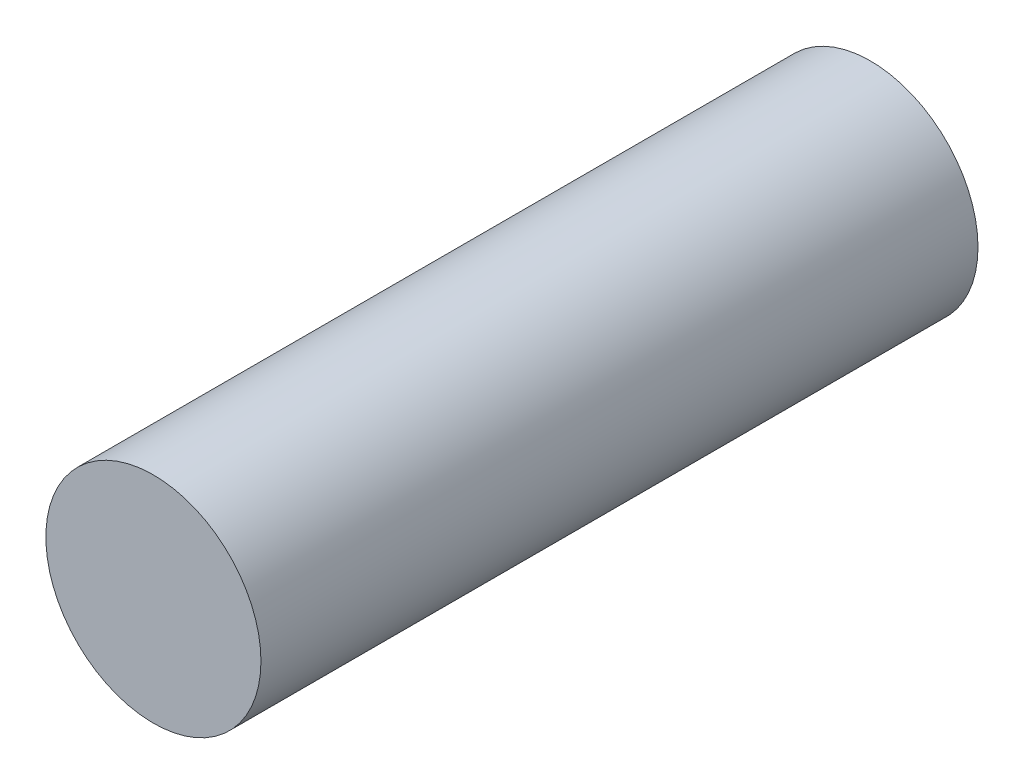
from build123d import *

# Parameters (mm, degrees)
SKETCH1_R           = 0.15
BOSS_EXTRUDE1_DEPTH = 1


with BuildPart() as part:
    # Sketch1 → Boss-Extrude1 (new body)
    with BuildSketch(Plane.XY):
        Circle(SKETCH1_R)
    extrude(amount=BOSS_EXTRUDE1_DEPTH)


solid = part.part
